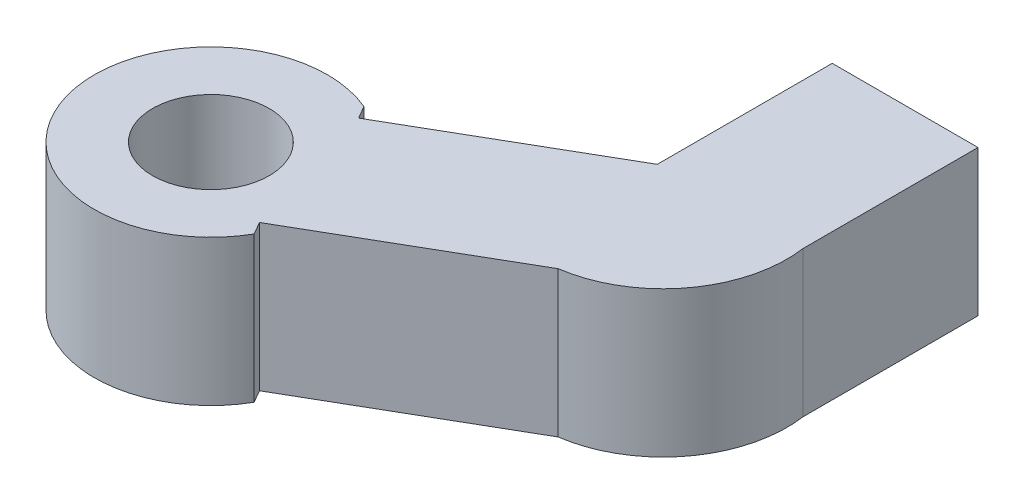
from build123d import *

# Parameters (mm, degrees)
SKETCH1_R           = 2
BOSS_EXTRUDE2_DEPTH = 2.5


with BuildPart() as part:
    # Sketch1 → Boss-Extrude2 (new body, symmetric)
    with BuildSketch(Plane(origin=(0, 0, 0), x_dir=(1, 0, 0), z_dir=(0, 1, 0))):
        with BuildLine():
            Line((0, 0), (-6.495190528, -3.75))
            Line((-6.495190528, -3.75), (-6.745190528, -3.316987298))
            ThreePointArc((-6.745190528, -3.316987298), (-12.108900988, -8.267189567), (-4.845190528, -8.983012702))
            Line((-4.845190528, -8.983012702), (-5.095190528, -8.55))
            Line((-5.095190528, -8.55), (1.4, -4.8))
            ThreePointArc((1.4, -4.8), (4.191681084, -3.143760813), (5, 0))
            Line((5, 0), (5, 6))
            Line((5, 6), (0, 6))
            Line((0, 6), (0, 0))
        make_face()
        with Locations((-8.316447957, -6.99545846)):
            Circle(SKETCH1_R, mode=Mode.SUBTRACT)
    extrude(amount=BOSS_EXTRUDE2_DEPTH, both=True)


solid = part.part
